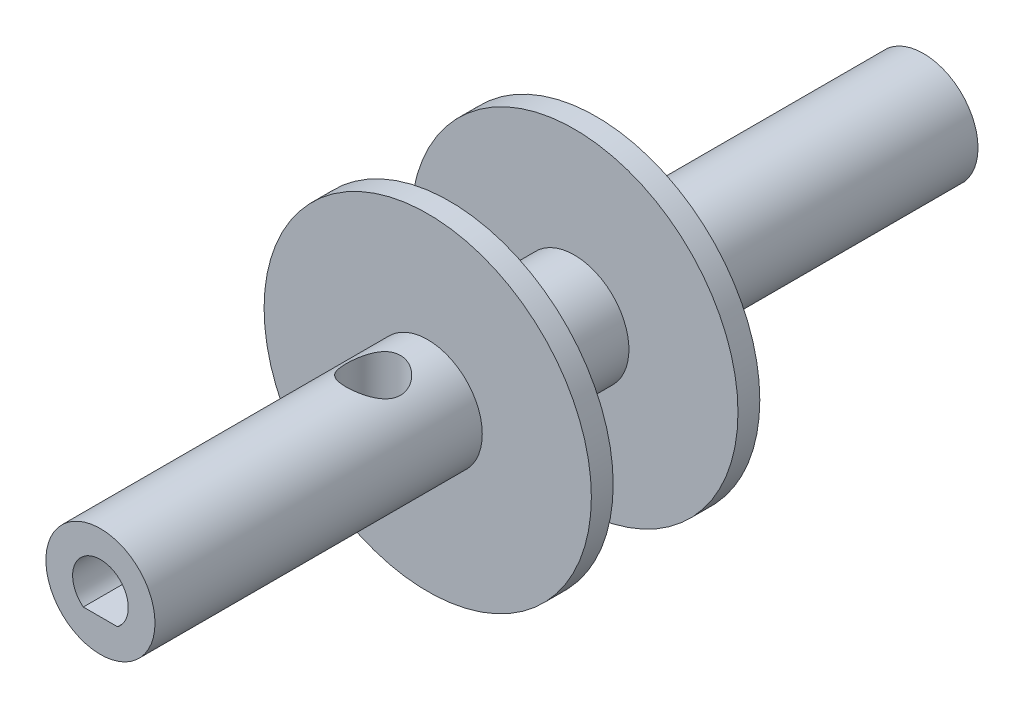
from build123d import *

# Parameters (mm, degrees)
SKETCH1_R               = 6.35
BOSS_EXTRUDE1_DEPTH     = 95.8088
SKETCH4_R               = 3.175
CUT_EXTRUDE2_DEPTH      = 7.35
CUT_EXTRUDE2_DEPTH_BACK = 7.35
SKETCH5_R               = 19.05
BOSS_EXTRUDE2_DEPTH     = 2.54
SKETCH6_R               = 19.05
BOSS_EXTRUDE3_DEPTH     = 2.54
CUT_EXTRUDE4_DEPTH      = 27.94
CUT_EXTRUDE5_DEPTH      = 27.94


with BuildPart() as part:
    # Sketch1 → Boss-Extrude1 (new body)
    with BuildSketch(Plane.XY):
        Circle(SKETCH1_R)
    extrude(amount=BOSS_EXTRUDE1_DEPTH)

    # Sketch4 → Cut-Extrude2 (cut, two sides)
    with BuildSketch(Plane(origin=(0, 0, 0), x_dir=(1, 0, 0), z_dir=(0, 1, 0))) as cut_extrude2_sk:
        with Locations((0, -64.0588)):
            Circle(SKETCH4_R)
        with Locations((0, -31.75)):
            Circle(SKETCH4_R)
    extrude(amount=CUT_EXTRUDE2_DEPTH, mode=Mode.SUBTRACT)
    extrude(cut_extrude2_sk.sketch, amount=-CUT_EXTRUDE2_DEPTH_BACK, mode=Mode.SUBTRACT)

    # Sketch5 → Boss-Extrude2 (add)
    with BuildSketch(Plane.XY.offset(57.7088)):
        Circle(SKETCH5_R)
    extrude(amount=-BOSS_EXTRUDE2_DEPTH)

    # Sketch6 → Boss-Extrude3 (add)
    with BuildSketch(Plane(origin=(0, 0, 38.1), x_dir=(-1, 0, 0), z_dir=(0, 0, -1))):
        Circle(SKETCH6_R)
    extrude(amount=-BOSS_EXTRUDE3_DEPTH)

    # Sketch2 → Cut-Extrude4 (cut)
    with BuildSketch(Plane.XY.offset(95.8088)):
        with BuildLine():
            Line((-1.992888597, -2.5527), (1.992888597, -2.5527))
            ThreePointArc((1.992888597, -2.5527), (0, 3.2385), (-1.992888597, -2.5527))
        make_face()
    extrude(amount=-CUT_EXTRUDE4_DEPTH, mode=Mode.SUBTRACT)

    # Sketch7 → Cut-Extrude5 (cut)
    with BuildSketch(Plane(origin=(0, 0, 0), x_dir=(-1, 0, 0), z_dir=(0, 0, -1))):
        with BuildLine():
            Line((-2.5527, 1.992888597), (-2.5527, -1.992888597))
            ThreePointArc((-2.5527, -1.992888597), (1.053793931, -3.06225417), (3.2385, 0))
            ThreePointArc((3.2385, 0), (1.053793931, 3.06225417), (-2.5527, 1.992888597))
        make_face()
    extrude(amount=-CUT_EXTRUDE5_DEPTH, mode=Mode.SUBTRACT)


solid = part.part
